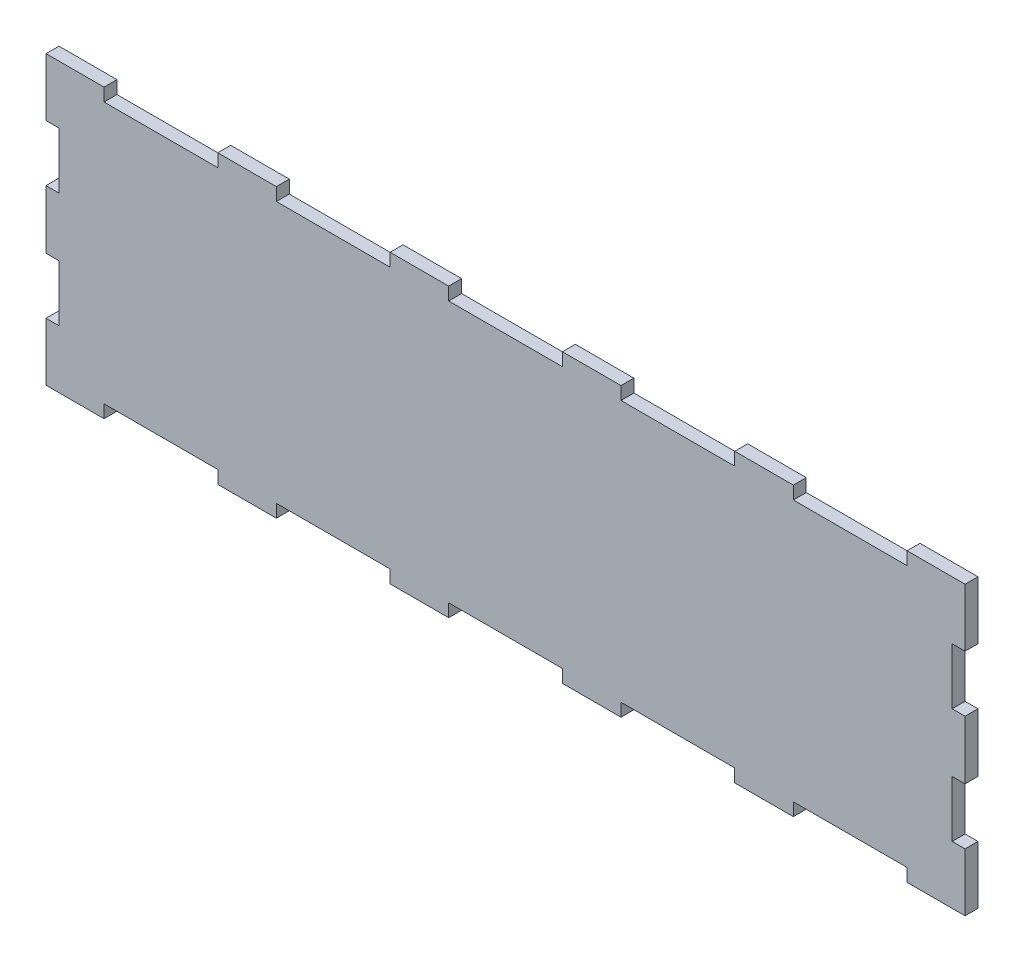
from build123d import *

# Parameters (mm, degrees)
SKETCH1_W           = 406.4
SKETCH1_H           = 127
BOSS_EXTRUDE1_DEPTH = 5.715
SKETCH2_W           = 50.8
SKETCH2_H           = 5.715
TOP_JIGSAW_DEPTH    = 6.715
SKETCH3_W           = 5.715
SKETCH3_H           = 25.4
RIGHT_JIGSAW_DEPTH  = 6.715
SKETCH4_W           = 0.254
SKETCH4_H           = 5.715
SKETCH4_W_2         = 5.715
SKETCH4_H_2         = 0.254
BOSS_EXTRUDE2_DEPTH = 5.715


with BuildPart() as part:
    # Sketch1 → Boss-Extrude1 (new body)
    with BuildSketch(Plane.XY):
        Rectangle(SKETCH1_W, SKETCH1_H)
    extrude(amount=BOSS_EXTRUDE1_DEPTH)

    # Sketch2 → Top Jigsaw (cut, through all)
    with BuildSketch(Plane.XY.offset(5.715)):
        with Locations((-152.4, 60.6425)):
            Rectangle(SKETCH2_W, SKETCH2_H)
        with Locations((-76.2, 60.6425)):
            Rectangle(SKETCH2_W, SKETCH2_H)
        with Locations((0, 60.6425)):
            Rectangle(SKETCH2_W, SKETCH2_H)
        with Locations((76.2, 60.6425)):
            Rectangle(SKETCH2_W, SKETCH2_H)
        with Locations((152.4, 60.6425)):
            Rectangle(SKETCH2_W, SKETCH2_H)
    top_jigsaw = extrude(amount=-TOP_JIGSAW_DEPTH, mode=Mode.SUBTRACT)

    # Bottom Jigsaw: Top Jigsaw across plane
    add(top_jigsaw.mirror(Plane.ZX), mode=Mode.SUBTRACT)

    # Sketch3 → Right Jigsaw (cut, through all)
    with BuildSketch(Plane.XY.offset(5.715)):
        with Locations((200.3425, 25.4)):
            Rectangle(SKETCH3_W, SKETCH3_H)
        with Locations((200.3425, -25.4)):
            Rectangle(SKETCH3_W, SKETCH3_H)
    right_jigsaw = extrude(amount=-RIGHT_JIGSAW_DEPTH, mode=Mode.SUBTRACT)

    # Mirror2: Right Jigsaw across plane
    add(right_jigsaw.mirror(Plane(origin=(0, 0, 0), x_dir=(0, 0, 1), z_dir=(1, 0, 0))), mode=Mode.SUBTRACT)

    # Sketch4 → Boss-Extrude2 (add)
    with BuildSketch(Plane.XY.offset(5.715)):
        with Locations((-177.673, 60.6425)):
            Rectangle(SKETCH4_W, SKETCH4_H)
        with Locations((-127.127, 60.6425)):
            Rectangle(SKETCH4_W, SKETCH4_H)
        with Locations((-101.473, 60.6425)):
            Rectangle(SKETCH4_W, SKETCH4_H)
        with Locations((-50.927, 60.6425)):
            Rectangle(SKETCH4_W, SKETCH4_H)
        with Locations((-25.273, 60.6425)):
            Rectangle(SKETCH4_W, SKETCH4_H)
        with Locations((25.273, 60.6425)):
            Rectangle(SKETCH4_W, SKETCH4_H)
        with Locations((50.927, 60.6425)):
            Rectangle(SKETCH4_W, SKETCH4_H)
        with Locations((101.473, 60.6425)):
            Rectangle(SKETCH4_W, SKETCH4_H)
        with Locations((127.127, 60.6425)):
            Rectangle(SKETCH4_W, SKETCH4_H)
        with Locations((177.673, 60.6425)):
            Rectangle(SKETCH4_W, SKETCH4_H)
        with Locations((200.3425, 37.973)):
            Rectangle(SKETCH4_W_2, SKETCH4_H_2)
        with Locations((200.3425, 12.827)):
            Rectangle(SKETCH4_W_2, SKETCH4_H_2)
        with Locations((-200.3425, 37.973)):
            Rectangle(SKETCH4_W_2, SKETCH4_H_2)
        with Locations((-200.3425, 12.827)):
            Rectangle(SKETCH4_W_2, SKETCH4_H_2)
    boss_extrude2 = extrude(amount=-BOSS_EXTRUDE2_DEPTH)

    # Mirror3: Boss-Extrude2 across plane
    add(boss_extrude2.mirror(Plane.ZX))


solid = part.part
